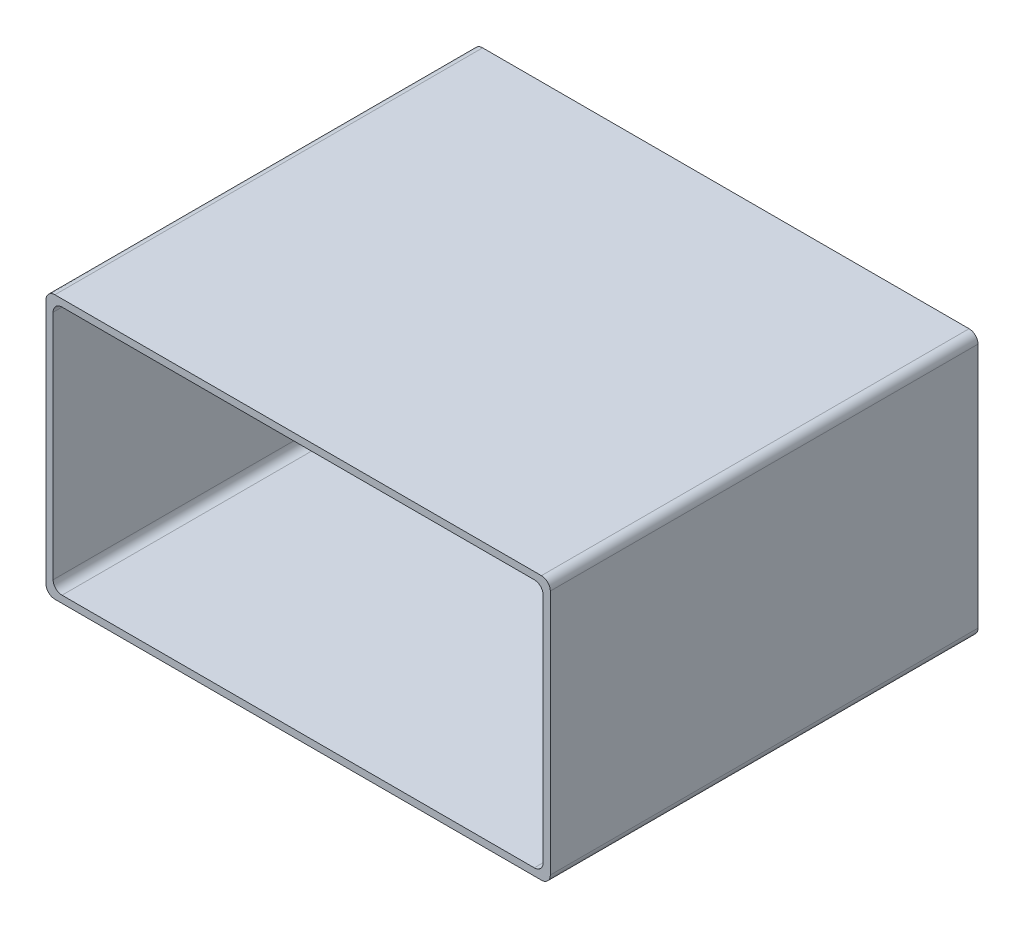
from build123d import *

# Parameters (mm, degrees)
ESQUISSE1_W        = 56.6
ESQUISSE1_H        = 29.6
ESQUISSE1_W_2      = 55
ESQUISSE1_H_2      = 28
BOSS_EXTRU_1_DEPTH = 48
CONG_1_R           = 1


with BuildPart() as part:
    # Esquisse1 → Boss.-Extru.1 (new body)
    with BuildSketch(Plane.XY):
        Rectangle(ESQUISSE1_W, ESQUISSE1_H)
        Rectangle(ESQUISSE1_W_2, ESQUISSE1_H_2, mode=Mode.SUBTRACT)
    extrude(amount=BOSS_EXTRU_1_DEPTH)

    # Congé1
    cong_1_edges = [part.edges().sort_by_distance(p)[0] for p in [
        (27.5, -14, 24),
        (27.5, 14, 24),
        (-27.5, 14, 24),
        (-27.5, -14, 24),
        (-28.3, 14.8, 24),
        (28.3, 14.8, 24),
        (28.3, -14.8, 24),
        (-28.3, -14.8, 24),
    ]]
    fillet(cong_1_edges, radius=CONG_1_R)


solid = part.part
